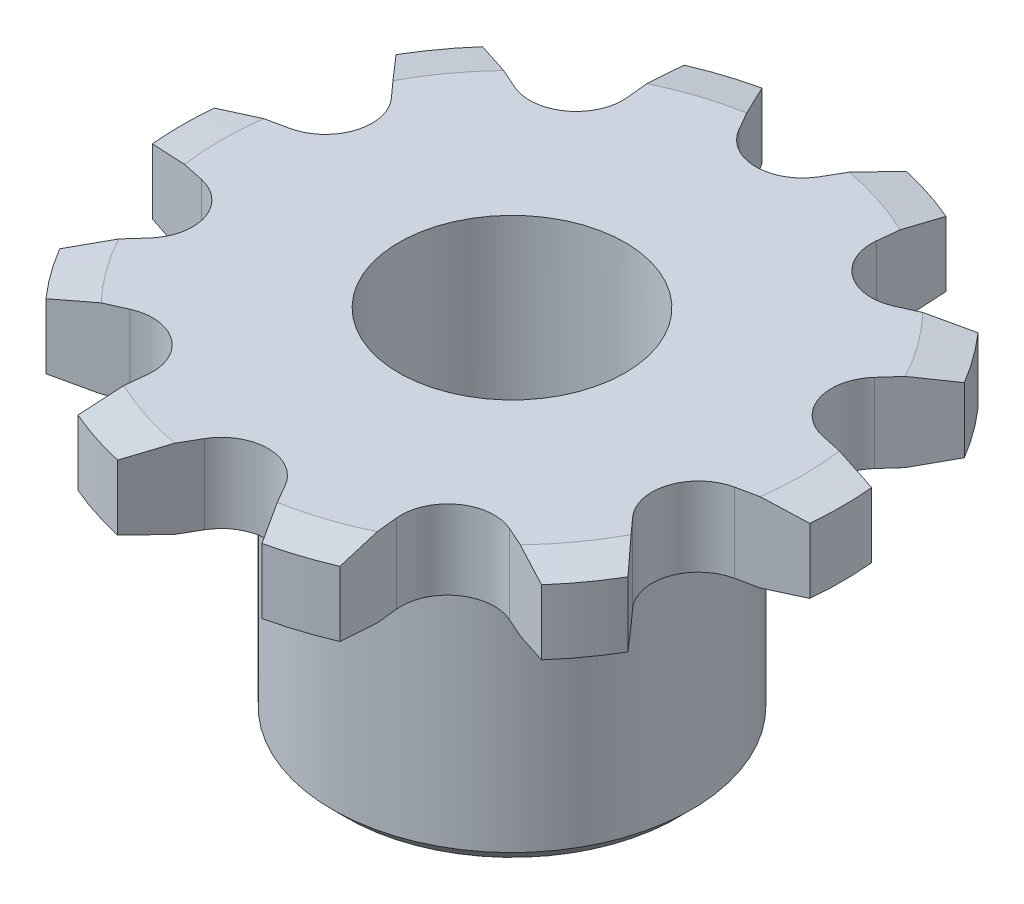
from build123d import *

# Parameters (mm, degrees)
CUT_EXTRUDE1_DEPTH = 2.794
CIRPATTERN1_COUNT  = 10
SKETCH3_R          = 4
CUT_EXTRUDE2_DEPTH = 13.7
SKETCH4_R          = 2.25
CUT_EXTRUDE3_DEPTH = 10
SKETCH5_R          = 2.25
CUT_EXTRUDE4_DEPTH = 10


with BuildPart() as part:
    # Sketch1 → Revolve2 (revolve)
    with BuildSketch(Plane.XY):
        Polygon((0, 0), (10.274515829, 0), (11.676645231, -0.247233244), (11.676645231, -2.546766756), (10.274515829, -2.794), (6.35, -2.794), (6.35, -12.2), (5.85, -12.7), (0, -12.7), align=None)
    revolve(axis=Axis((0, 0, 0), (0, -1, 0)))

    # Sketch2 → Cut-Extrude1 (cut)
    with BuildSketch(Plane(origin=(0, 0, 0), x_dir=(1, 0, 0), z_dir=(0, 1, 0))):
        with BuildLine():
            Line((1.428941916, 9.449515829), (2.551819083, 11.394396132))
            ThreePointArc((2.551819083, 11.394396132), (0, 11.676645231), (-2.551819083, 11.394396132))
            Line((-2.551819083, 11.394396132), (-1.428941916, 9.449515829))
            ThreePointArc((-1.428941916, 9.449515829), (0, 8.624515829), (1.428941916, 9.449515829))
        make_face()
    cut_extrude1 = extrude(amount=-CUT_EXTRUDE1_DEPTH, mode=Mode.SUBTRACT)

    # CirPattern1: Cut-Extrude1 ×10 about axis
    cirpattern1_axis = Axis((0, 0, 0), (0, 1, 0))
    for i in range(1, CIRPATTERN1_COUNT):
        add(cut_extrude1.rotate(cirpattern1_axis, i * 360 / CIRPATTERN1_COUNT), mode=Mode.SUBTRACT)

    # Sketch3 → Cut-Extrude2 (cut, through all)
    with BuildSketch(Plane.XZ.offset(12.7)):
        Circle(SKETCH3_R)
    extrude(amount=-CUT_EXTRUDE2_DEPTH, mode=Mode.SUBTRACT)

    # Sketch4 → Cut-Extrude3 (cut)
    with BuildSketch(Plane(origin=(0, 0, 0), x_dir=(0, 0, -1), z_dir=(1, 0, 0))):
        with Locations((0, -7.747)):
            Circle(SKETCH4_R)
    extrude(amount=-CUT_EXTRUDE3_DEPTH, mode=Mode.SUBTRACT)

    # Sketch5 → Cut-Extrude4 (cut)
    with BuildSketch(Plane.XY):
        with Locations((0, -7.497)):
            Circle(SKETCH5_R)
    extrude(amount=-CUT_EXTRUDE4_DEPTH, mode=Mode.SUBTRACT)


solid = part.part
